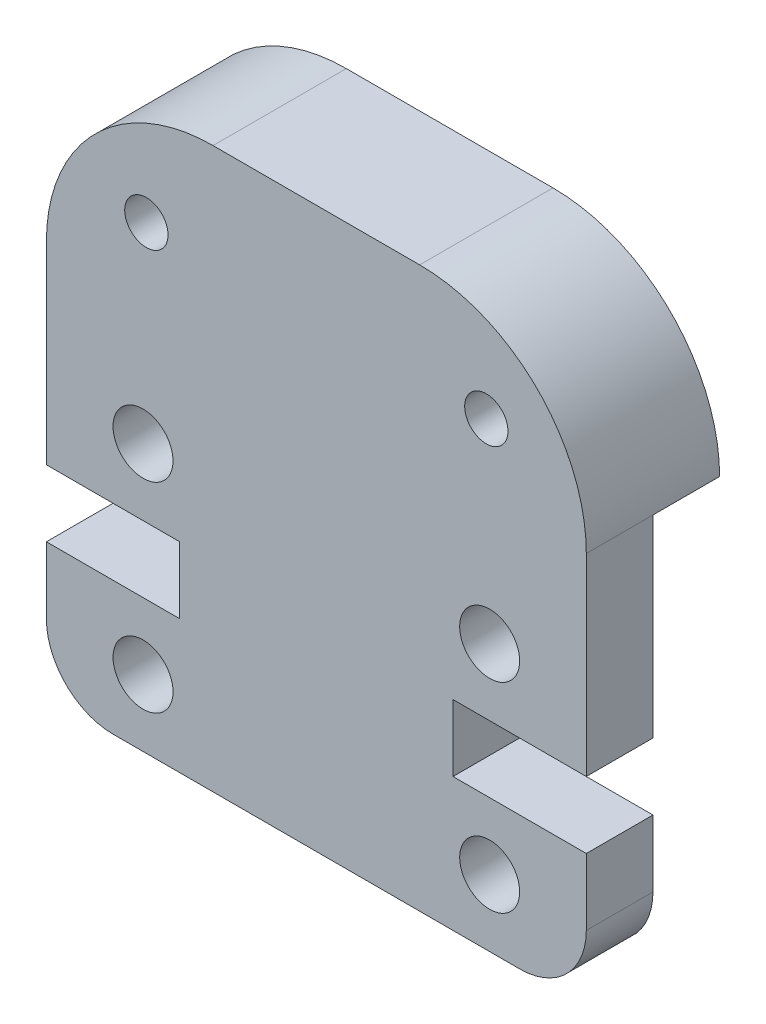
from build123d import *

# Parameters (mm, degrees)
SKETCH1_R           = 0.9
SKETCH1_R_2         = 0.65
BOSS_EXTRUDE1_DEPTH = 4
SKETCH2_W           = 16.2
SKETCH2_H           = 11.795
CUT_EXTRUDE1_DEPTH  = 2


with BuildPart() as part:
    # Sketch1 → Boss-Extrude1 (new body)
    with BuildSketch(Plane.XY):
        with BuildLine():
            Line((0, 6), (0, 11.795))
            ThreePointArc((0, 11.795), (1.464466094, 15.330533906), (5, 16.795))
            Line((5, 16.795), (11.2, 16.795))
            ThreePointArc((11.2, 16.795), (14.735533906, 15.330533906), (16.2, 11.795))
            Line((16.2, 11.795), (16.2, 6))
            Line((16.2, 6), (12.2, 6))
            Line((12.2, 6), (12.2, 4))
            Line((12.2, 4), (16.2, 4))
            Line((16.2, 4), (16.2, 2))
            ThreePointArc((16.2, 2), (15.614213562, 0.585786438), (14.2, 0))
            Line((14.2, 0), (2, 0))
            ThreePointArc((2, 0), (0.585786438, 0.585786438), (0, 2))
            Line((0, 2), (0, 4))
            Line((0, 4), (4, 4))
            Line((4, 4), (4, 6))
            Line((4, 6), (0, 6))
        make_face()
        with Locations((13.3, 2)):
            Circle(SKETCH1_R, mode=Mode.SUBTRACT)
        with Locations((13.3, 8)):
            Circle(SKETCH1_R, mode=Mode.SUBTRACT)
        with Locations((3, 13.795)):
            Circle(SKETCH1_R_2, mode=Mode.SUBTRACT)
        with Locations((13.2, 13.795)):
            Circle(SKETCH1_R_2, mode=Mode.SUBTRACT)
        with Locations((2.9, 8)):
            Circle(SKETCH1_R, mode=Mode.SUBTRACT)
        with Locations((2.9, 2)):
            Circle(SKETCH1_R, mode=Mode.SUBTRACT)
    extrude(amount=BOSS_EXTRUDE1_DEPTH)

    # Sketch2 → Cut-Extrude1 (cut)
    with BuildSketch(Plane.XY):
        with Locations((8.1, 5.8975)):
            Rectangle(SKETCH2_W, SKETCH2_H)
    extrude(amount=CUT_EXTRUDE1_DEPTH, mode=Mode.SUBTRACT)


solid = part.part
